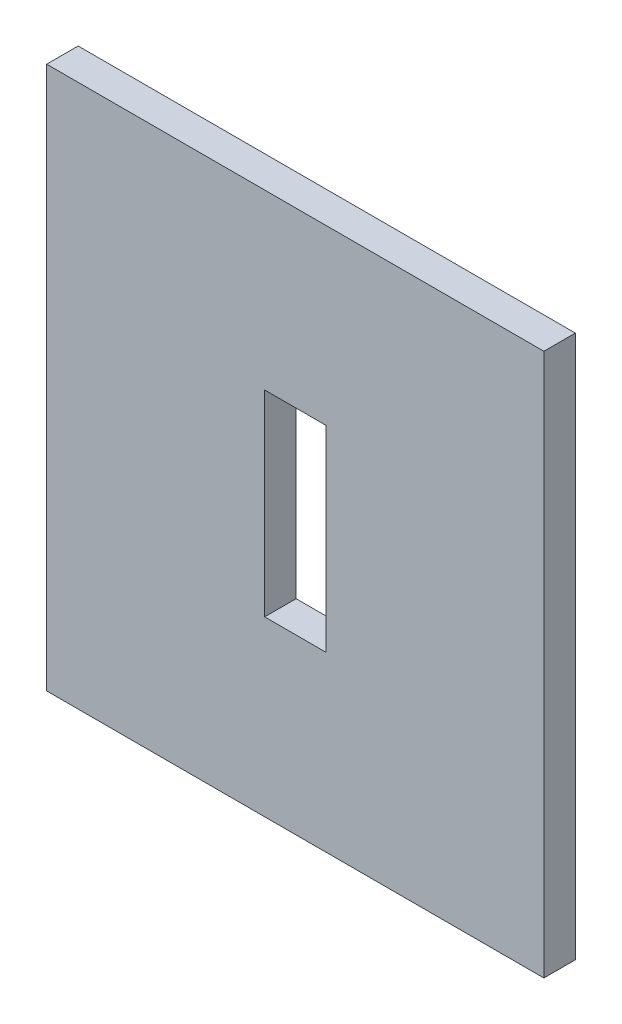
from build123d import *

# Parameters (mm, degrees)
SKETCH1_W           = 50.17
SKETCH1_H           = 54.77
BOSS_EXTRUDE1_DEPTH = 3.175
SKETCH3_W           = 6.18
SKETCH3_H           = 19.83
CUT_EXTRUDE2_DEPTH  = 4.175


with BuildPart() as part:
    # Sketch1 → Boss-Extrude1 (new body)
    with BuildSketch(Plane.XY):
        Rectangle(SKETCH1_W, SKETCH1_H)
    extrude(amount=BOSS_EXTRUDE1_DEPTH)

    # Sketch3 → Cut-Extrude2 (cut, through all)
    with BuildSketch(Plane.XY.offset(3.175)):
        Rectangle(SKETCH3_W, SKETCH3_H)
    extrude(amount=-CUT_EXTRUDE2_DEPTH, mode=Mode.SUBTRACT)


solid = part.part
